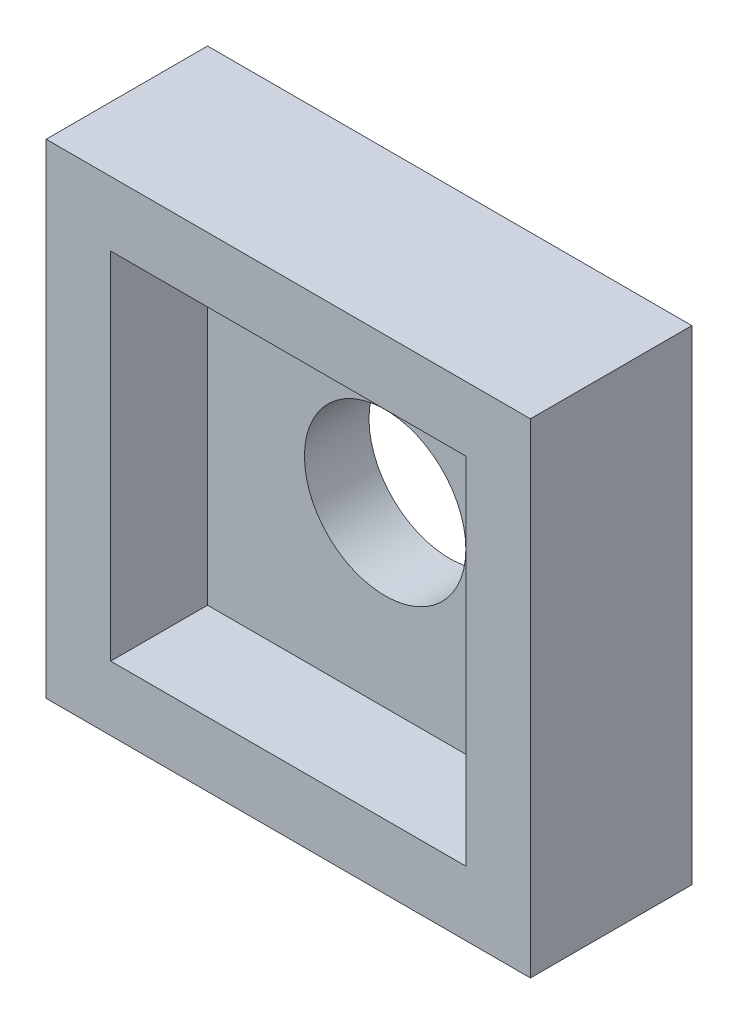
from build123d import *

# Parameters (mm, degrees)
SKETCH_1_W          = 15
SKETCH_1_H          = 15
EXTRUDE_2_DEPTH     = 5
SHELL_1_T           = -2
SKETCH_2_R          = 2.5
CUT_EXTRUDE_1_DEPTH = 5


with BuildPart() as part:
    # 草图1 → 凸台-拉伸2 (new body)
    with BuildSketch(Plane.XY):
        Rectangle(SKETCH_1_W, SKETCH_1_H)
    extrude(amount=EXTRUDE_2_DEPTH)

    # 抽壳1
    shell_1_openings = [part.faces().sort_by_distance(p)[0] for p in [
        (0, 0, 5),
    ]]
    offset(amount=SHELL_1_T, openings=shell_1_openings, kind=Kind.INTERSECTION)

    # 草图2 → 切除-拉伸1 (cut)
    with BuildSketch(Plane(origin=(0, 0, 0), x_dir=(-1, 0, 0), z_dir=(0, 0, -1))):
        Circle(SKETCH_2_R)
    extrude(amount=-CUT_EXTRUDE_1_DEPTH, mode=Mode.SUBTRACT)


solid = part.part
